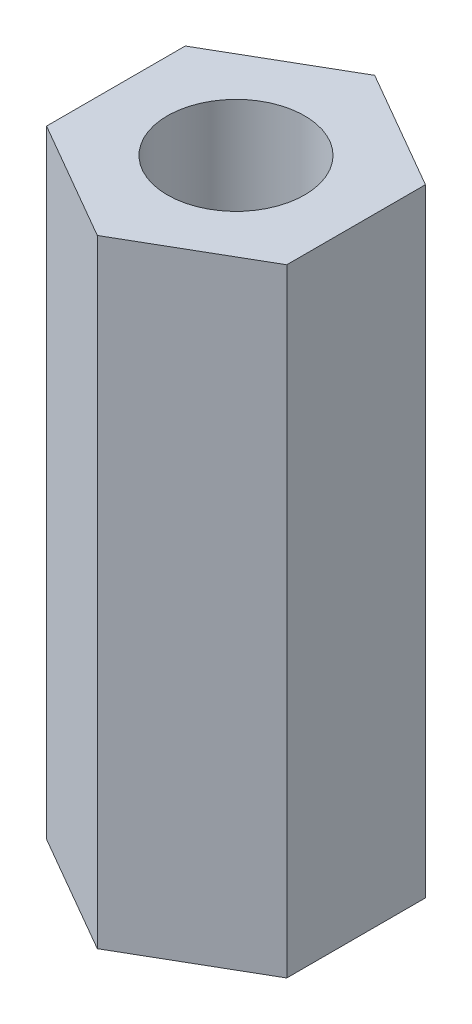
from build123d import *

# Parameters (mm, degrees)
SKETCH1_R           = 2
BOSS_EXTRUDE1_DEPTH = 18


with BuildPart() as part:
    # Sketch1 → Boss-Extrude1 (new body)
    with BuildSketch(Plane(origin=(0, 0, 0), x_dir=(1, 0, 0), z_dir=(0, 1, 0))):
        Polygon((-34.951809206, 18.248482245), (-38.451809206, 16.227756303), (-38.451809206, 12.186304419), (-34.951809206, 10.165578476), (-31.451809206, 12.186304419), (-31.451809206, 16.227756303), align=None)
        with Locations((-34.951809206, 14.207030361)):
            Circle(SKETCH1_R, mode=Mode.SUBTRACT)
    extrude(amount=BOSS_EXTRUDE1_DEPTH)


solid = part.part
